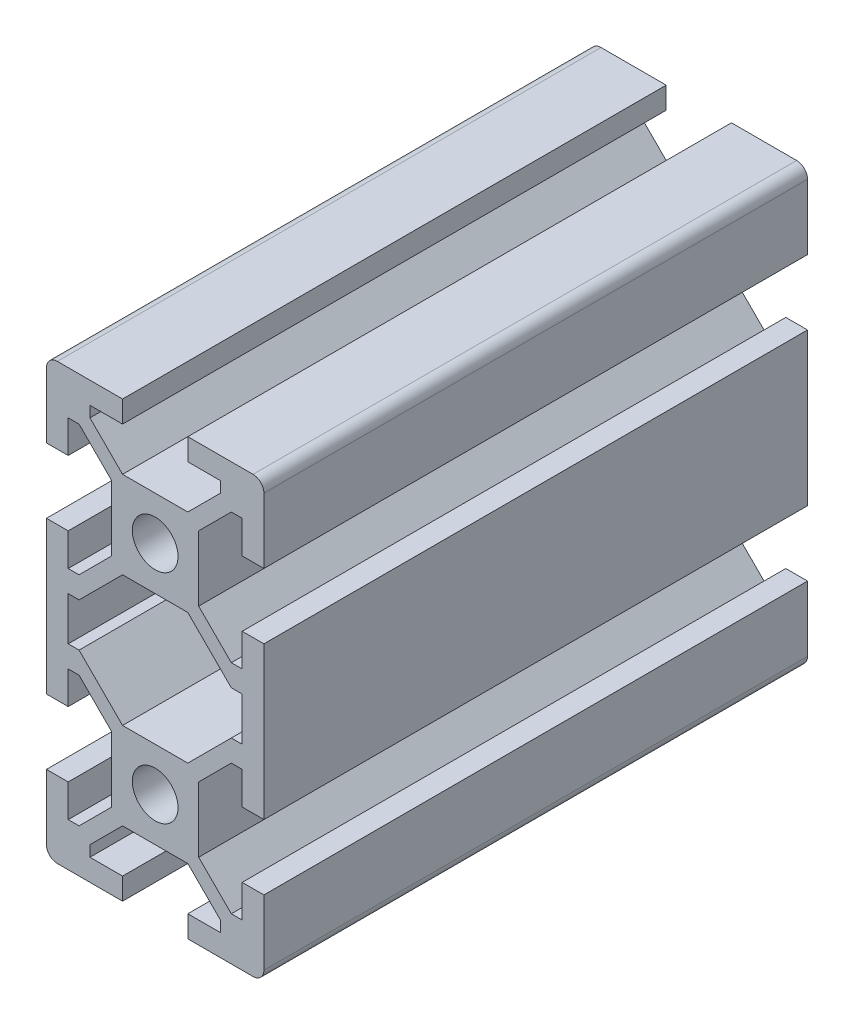
from build123d import *

# Parameters (mm, degrees)
SCHIZZO1_R                   = 2.1
ESTRUSIONE_ESTRUSIONE1_DEPTH = 50
RACCORDO1_R                  = 1


with BuildPart() as part:
    # Schizzo1 → Estrusione-Estrusione1 (new body)
    with BuildSketch(Plane.XY):
        Polygon((-3, 20), (-10, 20), (-10, 13), (-8, 13), (-8, 16), (-7, 16), (-4, 13), (-4, 7), (-7, 4), (-8, 4), (-8, 7), (-10, 7), (-10, -7), (-8, -7), (-8, -4), (-7, -4), (-4, -7), (-4, -13), (-7, -16), (-8, -16), (-8, -13), (-10, -13), (-10, -20), (-3, -20), (-3, -18), (-6, -18), (-6, -17), (-3, -14), (3, -14), (6, -17), (6, -18), (3, -18), (3, -20), (10, -20), (10, -13), (8, -13), (8, -16), (7, -16), (4, -13), (4, -7), (7, -4), (8, -4), (8, -7), (10, -7), (10, 7), (8, 7), (8, 4), (7, 4), (4, 7), (4, 13), (7, 16), (8, 16), (8, 13), (10, 13), (10, 20), (3, 20), (3, 18), (6, 18), (6, 17), (3, 14), (-3, 14), (-6, 17), (-6, 18), (-3, 18), align=None)
        Polygon((8, 2), (8, -2), (7, -2), (3, -6), (-3, -6), (-7, -2), (-8, -2), (-8, 2), (-7, 2), (-3, 6), (3, 6), (7, 2), align=None, mode=Mode.SUBTRACT)
        with Locations((0, 10)):
            Circle(SCHIZZO1_R, mode=Mode.SUBTRACT)
        with Locations((0, -10)):
            Circle(SCHIZZO1_R, mode=Mode.SUBTRACT)
    extrude(amount=ESTRUSIONE_ESTRUSIONE1_DEPTH)

    # Raccordo1
    raccordo1_edges = [part.edges().sort_by_distance(p)[0] for p in [
        (-10, 20, 25),
        (10, 20, 25),
        (10, -20, 25),
        (-10, -20, 25),
    ]]
    fillet(raccordo1_edges, radius=RACCORDO1_R)


solid = part.part
